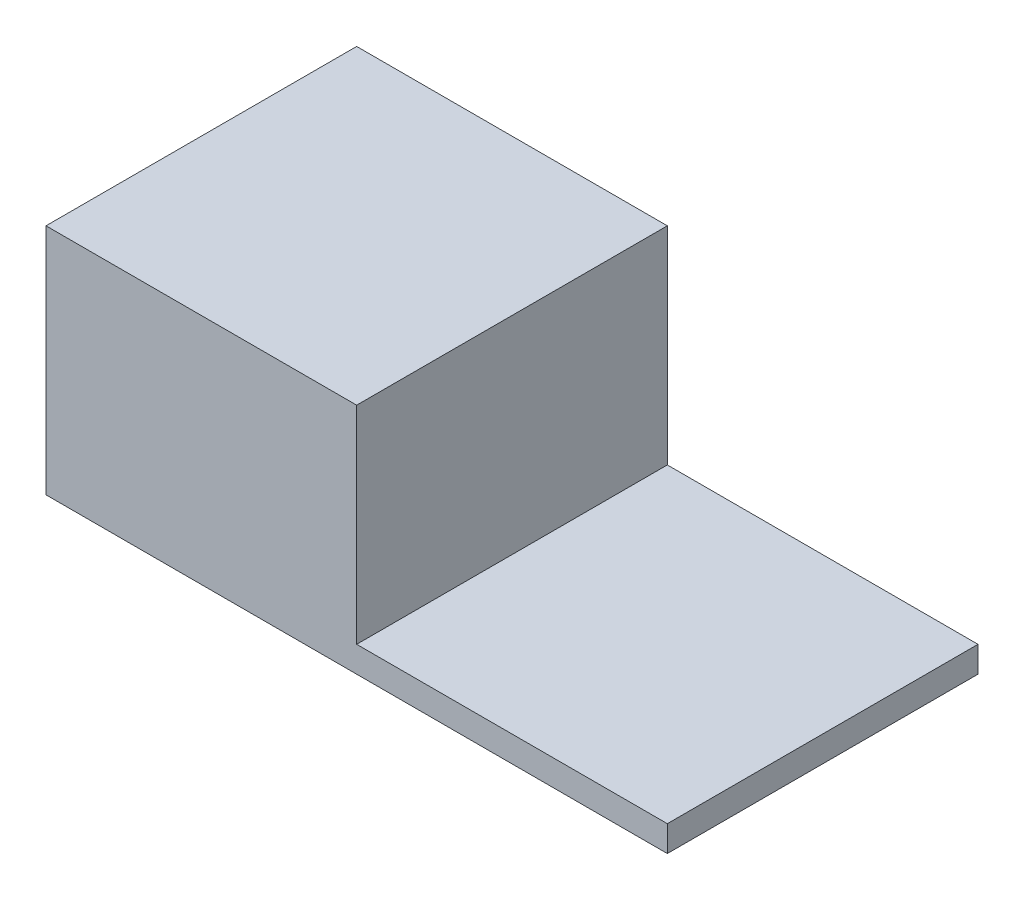
from build123d import *

# Parameters (mm, degrees)
SKETCH_1_W      = 1200
SKETCH_1_H      = 50
SKETCH_1_W_2    = 600
SKETCH_1_H_2    = 400
EXTRUDE_1_DEPTH = 600


with BuildPart() as part:
    # ｽｹｯﾁ1 → ﾎﾞｽ - 押し出し1 (new body)
    with BuildSketch(Plane.XY):
        with Locations((600, 25)):
            Rectangle(SKETCH_1_W, SKETCH_1_H)
        with Locations((300, 250)):
            Rectangle(SKETCH_1_W_2, SKETCH_1_H_2)
    extrude(amount=EXTRUDE_1_DEPTH)


solid = part.part
